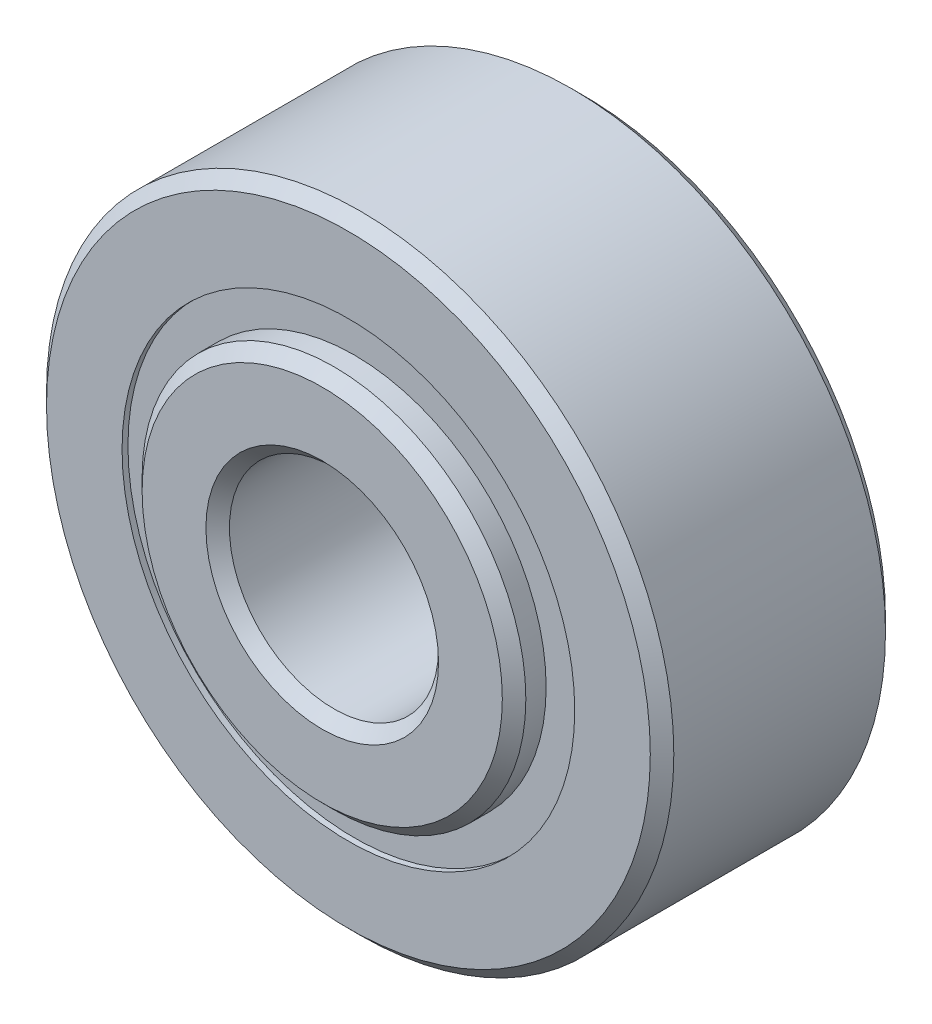
from build123d import *

# Parameters (mm, degrees)
CIRPATTERN1_COUNT = 10
SKETCH5_W         = 0.860693193
SKETCH5_H         = 0.523407472


with BuildPart() as part:
    # Sketch1 → Revolve1 (revolve)
    with BuildSketch(Plane(origin=(0, 0, 0), x_dir=(0, 0, -1), z_dir=(1, 0, 0))):
        with BuildLine():
            Line((1.607058, 4.7625), (-1.607058, 4.7625))
            Line((-1.607058, 4.7625), (-1.78562, 4.583938))
            Line((-1.78562, 4.583938), (-1.78562, 3.436703736))
            Line((-1.78562, 3.436703736), (-0.793608889, 3.436703736))
            ThreePointArc((-0.793608889, 3.436703736), (0, 4.010645807), (0.793608889, 3.436703736))
            Line((0.793608889, 3.436703736), (1.78562, 3.436703736))
            Line((1.78562, 3.436703736), (1.78562, 4.583938))
            Line((1.78562, 4.583938), (1.607058, 4.7625))
        make_face()
    revolve(axis=Axis((0, 0, 1.78562), (0, 0, -1)))


with BuildPart() as body_2:
    # Sketch3 → Revolve3 (revolve)
    with BuildSketch(Plane(origin=(0, 0, 0), x_dir=(0, 0, -1), z_dir=(1, 0, 0))):
        with BuildLine():
            Line((-2.18313, 1.766062), (-2.18313, 2.734734264))
            Line((-2.18313, 2.734734264), (-2.004568, 2.913296264))
            Line((-2.004568, 2.913296264), (-0.793608889, 2.913296264))
            ThreePointArc((-0.793608889, 2.913296264), (0, 2.339354193), (0.793608889, 2.913296264))
            Line((0.793608889, 2.913296264), (2.004568, 2.913296264))
            Line((2.004568, 2.913296264), (2.18313, 2.734734264))
            Line((2.18313, 2.734734264), (2.18313, 1.766062))
            Line((2.18313, 1.766062), (2.004568, 1.5875))
            Line((2.004568, 1.5875), (-2.004568, 1.5875))
            Line((-2.004568, 1.5875), (-2.18313, 1.766062))
        make_face()
    revolve(axis=Axis((0, 0, 1.78562), (0, 0, -1)))


with BuildPart() as body_3:
    # Sketch4 → Revolve4 (revolve)
    with BuildSketch(Plane(origin=(0, 0, 0), x_dir=(0, 0, -1), z_dir=(1, 0, 0))):
        with BuildLine():
            Line((-0.835645807, 3.175), (0.835645807, 3.175))
            ThreePointArc((0.835645807, 3.175), (0, 4.010645807), (-0.835645807, 3.175))
        make_face()
    revolve(axis=Axis((0, 3.175, 0.835645807), (0, 0, -1)))


with BuildPart() as cirpattern1_1:
    # CirPattern1: pattern copy
    add(body_3.part.rotate(Axis((0, 0, -1.78562), (0, 0, 1)), 1 * 360 / CIRPATTERN1_COUNT))


with BuildPart() as cirpattern1_2:
    # CirPattern1: pattern copy
    add(body_3.part.rotate(Axis((0, 0, -1.78562), (0, 0, 1)), 2 * 360 / CIRPATTERN1_COUNT))


with BuildPart() as cirpattern1_3:
    # CirPattern1: pattern copy
    add(body_3.part.rotate(Axis((0, 0, -1.78562), (0, 0, 1)), 3 * 360 / CIRPATTERN1_COUNT))


with BuildPart() as cirpattern1_4:
    # CirPattern1: pattern copy
    add(body_3.part.rotate(Axis((0, 0, -1.78562), (0, 0, 1)), 4 * 360 / CIRPATTERN1_COUNT))


with BuildPart() as cirpattern1_5:
    # CirPattern1: pattern copy
    add(body_3.part.rotate(Axis((0, 0, -1.78562), (0, 0, 1)), 5 * 360 / CIRPATTERN1_COUNT))


with BuildPart() as cirpattern1_6:
    # CirPattern1: pattern copy
    add(body_3.part.rotate(Axis((0, 0, -1.78562), (0, 0, 1)), 6 * 360 / CIRPATTERN1_COUNT))


with BuildPart() as cirpattern1_7:
    # CirPattern1: pattern copy
    add(body_3.part.rotate(Axis((0, 0, -1.78562), (0, 0, 1)), 7 * 360 / CIRPATTERN1_COUNT))


with BuildPart() as cirpattern1_8:
    # CirPattern1: pattern copy
    add(body_3.part.rotate(Axis((0, 0, -1.78562), (0, 0, 1)), 8 * 360 / CIRPATTERN1_COUNT))


with BuildPart() as cirpattern1_9:
    # CirPattern1: pattern copy
    add(body_3.part.rotate(Axis((0, 0, -1.78562), (0, 0, 1)), 9 * 360 / CIRPATTERN1_COUNT))


with BuildPart() as body_13:
    # Sketch5 → Revolve5 (revolve)
    with BuildSketch(Plane(origin=(0, 0, 0), x_dir=(0, 0, -1), z_dir=(1, 0, 0))):
        with Locations((-1.265992404, 3.175)):
            Rectangle(SKETCH5_W, SKETCH5_H)
        with Locations((1.265992404, 3.175)):
            Rectangle(SKETCH5_W, SKETCH5_H)
    revolve(axis=Axis((0, 0, 1.78562), (0, 0, -1)))


solid = Compound([part.part, body_2.part, body_3.part, cirpattern1_1.part, cirpattern1_2.part, cirpattern1_3.part, cirpattern1_4.part, cirpattern1_5.part, cirpattern1_6.part, cirpattern1_7.part, cirpattern1_8.part, cirpattern1_9.part, body_13.part])
